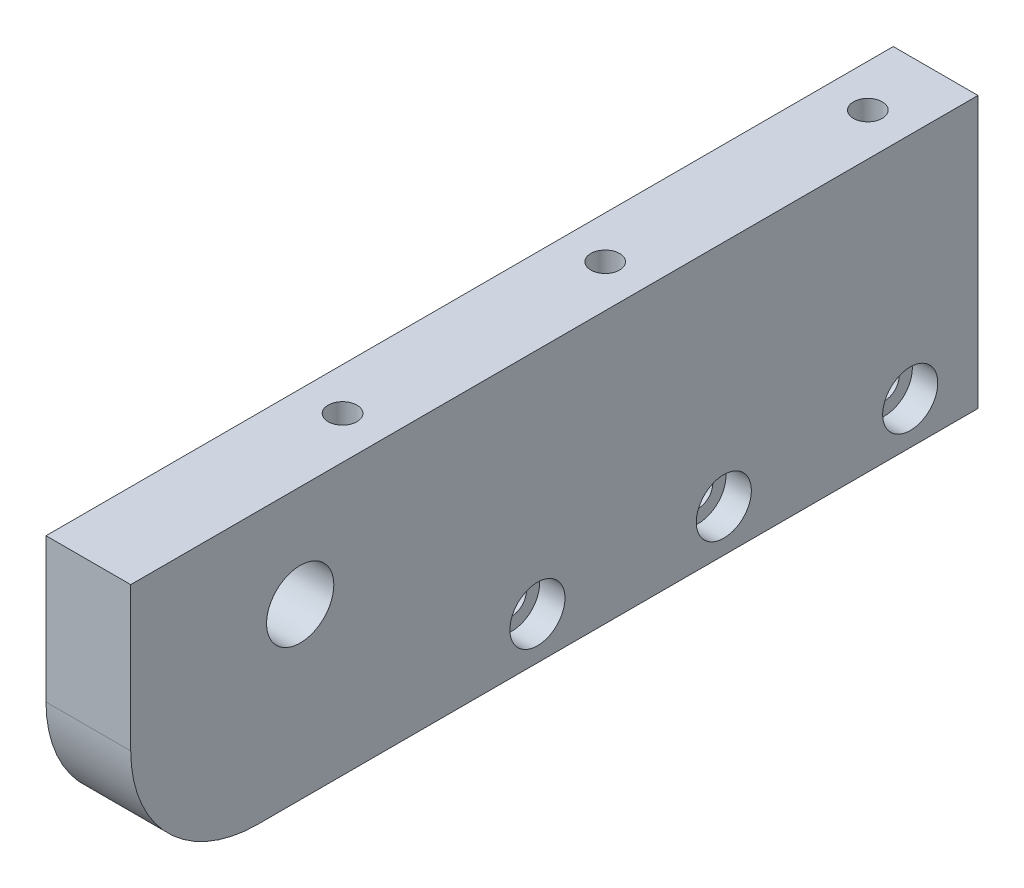
from build123d import *

# Parameters (mm, degrees)
SKETCH1_W                      = 100
SKETCH1_H                      = 32
SKETCH1_R                      = 3.96875
BOSS_EXTRUDE1_DEPTH            = 10
FILLET1_R                      = 15
CBORE_FOR_M3_SHCS_D            = 3.4
CBORE_FOR_M3_SHCS_DEPTH        = 23
CBORE_FOR_M3_SHCS_CBORE_D      = 6.5
CBORE_FOR_M3_SHCS_CBORE_DEPTH  = 3
CBORE_FOR_M3_SHCS_TIP          = 1.021463052
CBORE_FOR_M3_SHCS1_D           = 3.4
CBORE_FOR_M3_SHCS1_DEPTH       = 23
CBORE_FOR_M3_SHCS1_CBORE_D     = 6.5
CBORE_FOR_M3_SHCS1_CBORE_DEPTH = 3
CBORE_FOR_M3_SHCS1_TIP         = 1.021463052


with BuildPart() as part:
    # Sketch1 → Boss-Extrude1 (new body)
    with BuildSketch(Plane(origin=(0, 0, 0), x_dir=(0, 0, -1), z_dir=(1, 0, 0))):
        Rectangle(SKETCH1_W, SKETCH1_H)
        with Locations((-30, 4)):
            Circle(SKETCH1_R, mode=Mode.SUBTRACT)
    extrude(amount=BOSS_EXTRUDE1_DEPTH)

    # Fillet1
    fillet1_edges = [part.edges().sort_by_distance(p)[0] for p in [
        (5, -16, 50),
    ]]
    fillet(fillet1_edges, radius=FILLET1_R)

    # CBORE for M3 SHCS
    with Locations(Plane(origin=(-726.293536786, 26, -1323.282701689), x_dir=(1, 0, 0), z_dir=(0, 1, 0))):
        with Locations((731.293536786, -1281.282701689), (731.293536786, -1343.282701689), (621.293536786, -1281.282701689), (621.293536786, -1365.282701689), (621.293536786, -1323.282701689), (731.293536786, -1312.282701689)):
            CounterBoreHole(CBORE_FOR_M3_SHCS_D / 2, CBORE_FOR_M3_SHCS_CBORE_D / 2, CBORE_FOR_M3_SHCS_CBORE_DEPTH, depth=CBORE_FOR_M3_SHCS_DEPTH)
            with Locations((0, 0, -(CBORE_FOR_M3_SHCS_DEPTH + CBORE_FOR_M3_SHCS_TIP / 2))):  # 118° drill point
                Cone(0, CBORE_FOR_M3_SHCS_D / 2, CBORE_FOR_M3_SHCS_TIP, mode=Mode.SUBTRACT)

    # CBORE for M3 SHCS1
    with Locations(Plane(origin=(10, -904.012147263, -1323.282701689), x_dir=(0, 0, -1), z_dir=(1, 0, 0))):
        with Locations((-1281.282701689, 893.012147263), (-1325.282701689, 893.012147263), (-1303.282701689, 893.012147263)):
            CounterBoreHole(CBORE_FOR_M3_SHCS1_D / 2, CBORE_FOR_M3_SHCS1_CBORE_D / 2, CBORE_FOR_M3_SHCS1_CBORE_DEPTH, depth=CBORE_FOR_M3_SHCS1_DEPTH)
            with Locations((0, 0, -(CBORE_FOR_M3_SHCS1_DEPTH + CBORE_FOR_M3_SHCS1_TIP / 2))):  # 118° drill point
                Cone(0, CBORE_FOR_M3_SHCS1_D / 2, CBORE_FOR_M3_SHCS1_TIP, mode=Mode.SUBTRACT)


solid = part.part
